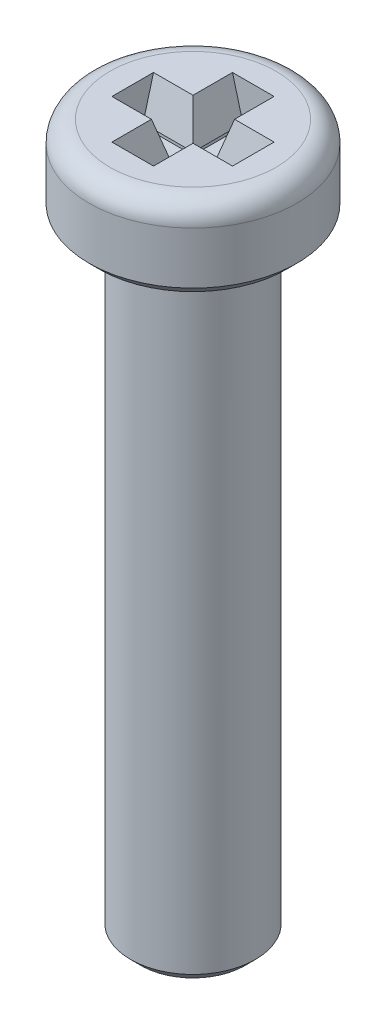
from build123d import *

# Parameters (mm, degrees)
CROQUIS1_R              = 2.5
SALIENTE_EXTRUIR1_DEPTH = 2
CROQUIS2_R              = 1.5
SALIENTE_EXTRUIR2_DEPTH = 15
CHAFL_N1_SIZE           = 0.25
REDONDEO1_R             = 0.5
CORTAR_EXTRUIR1_DEPTH   = 1
CHAFL_N2_SIZE           = 0.25
CHAFL_N2_SIZE2          = 0.933012702


with BuildPart() as part:
    # Croquis1 → Saliente-Extruir1 (new body)
    with BuildSketch(Plane(origin=(0, 0, 0), x_dir=(1, 0, 0), z_dir=(0, 1, 0))):
        Circle(CROQUIS1_R)
    extrude(amount=SALIENTE_EXTRUIR1_DEPTH)

    # Croquis2 → Saliente-Extruir2 (add)
    with BuildSketch(Plane.XZ):
        Circle(CROQUIS2_R)
    extrude(amount=SALIENTE_EXTRUIR2_DEPTH)

    # Chaflán1
    chafl_n1_edges = [part.edges().sort_by_distance(p)[0] for p in [
        (-2.5, 0, 0),
        (-1.5, -15, 0),
    ]]
    chamfer(chafl_n1_edges, length=CHAFL_N1_SIZE)

    # Redondeo1
    redondeo1_edges = [part.edges().sort_by_distance(p)[0] for p in [
        (-2.5, 2, 0),
    ]]
    fillet(redondeo1_edges, radius=REDONDEO1_R)

    # Croquis3 → Cortar-Extruir1 (cut)
    with BuildSketch(Plane(origin=(0, 2, 0), x_dir=(1, 0, 0), z_dir=(0, 1, 0))):
        Polygon((0.25, 0.25), (1.45, 0.25), (1.45, -0.25), (0.25, -0.25), (0.25, -1.45), (-0.25, -1.45), (-0.25, -0.25), (-1.45, -0.25), (-1.45, 0.25), (-0.25, 0.25), (-0.25, 1.45), (0.25, 1.45), align=None)
    extrude(amount=-CORTAR_EXTRUIR1_DEPTH, mode=Mode.SUBTRACT)

    # Chaflán2
    chafl_n2_edges = [part.edges().sort_by_distance(p)[0] for p in [
        (-0.25, 2, -0.85),
        (-0.85, 2, -0.25),
        (-0.85, 2, 0.25),
        (-0.25, 2, 0.85),
        (0.25, 2, 0.85),
        (0.85, 2, 0.25),
        (0.85, 2, -0.25),
        (0.25, 2, -0.85),
    ]]
    chafl_n2_side = [part.faces().sort_by_distance(p)[0] for p in [
        (-1.943431458, 2, 0),
    ]]
    chamfer(chafl_n2_edges, length=CHAFL_N2_SIZE, length2=CHAFL_N2_SIZE2, reference=chafl_n2_side[0])


solid = part.part
